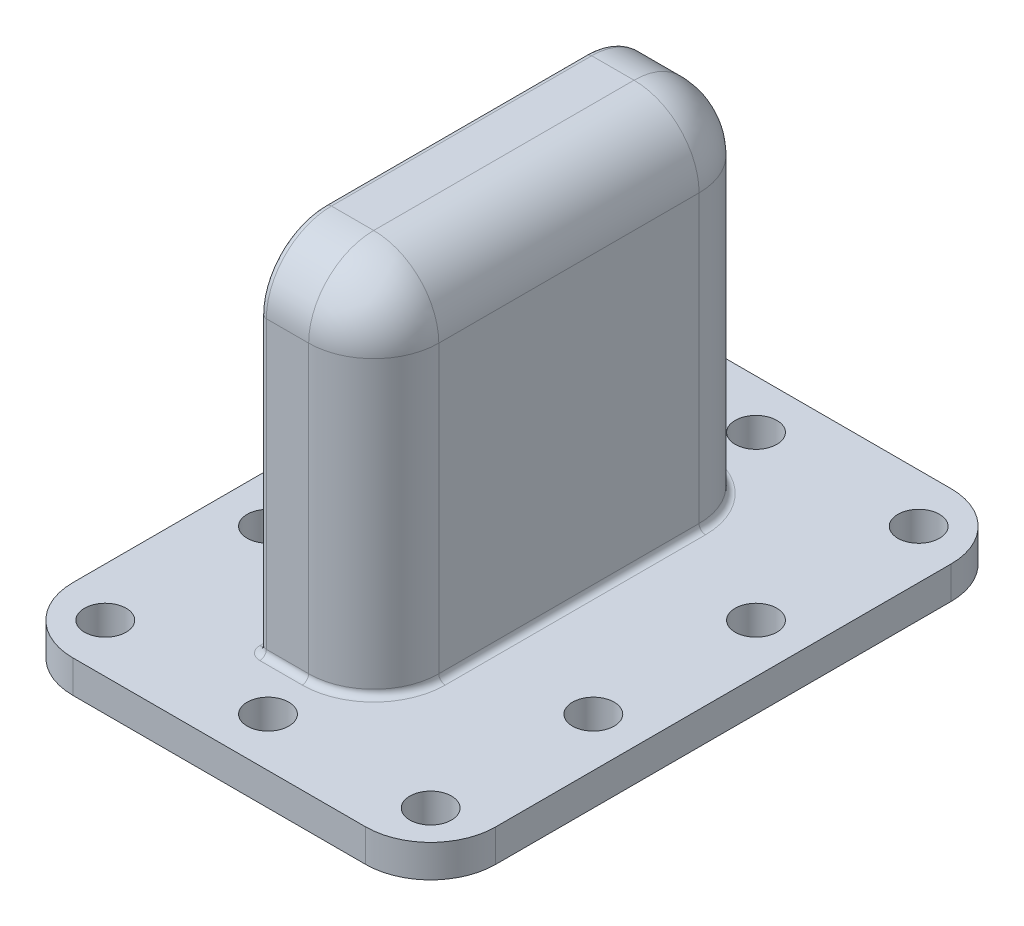
from build123d import *

# Parameters (mm, degrees)
SKETCH_1_W      = 65
SKETCH_1_H      = 90
SKETCH_1_R      = 3.2
EXTRUDE_1_DEPTH = 5
FILLET_1_R      = 10
SKETCH_2_W      = 17.5
SKETCH_2_H      = 60
EXTRUDE_2_DEPTH = 55
FILLET_2_R      = 10
FILLET_3_R      = 1


with BuildPart() as part:
    # 스케치1 → 보스-돌출1 (new body)
    with BuildSketch(Plane(origin=(0, 0, 0), x_dir=(1, 0, 0), z_dir=(0, 1, 0))):
        with Locations((0, -12.5)):
            Rectangle(SKETCH_1_W, SKETCH_1_H)
        with Locations((-25, 25)):
            Circle(SKETCH_1_R, mode=Mode.SUBTRACT)
        with Locations((25, 25)):
            Circle(SKETCH_1_R, mode=Mode.SUBTRACT)
        with Locations((25, 0)):
            Circle(SKETCH_1_R, mode=Mode.SUBTRACT)
        with Locations((-25, 0)):
            Circle(SKETCH_1_R, mode=Mode.SUBTRACT)
        with Locations((25, -50)):
            Circle(SKETCH_1_R, mode=Mode.SUBTRACT)
        with Locations((-25, -50)):
            Circle(SKETCH_1_R, mode=Mode.SUBTRACT)
        with Locations((0, 25)):
            Circle(SKETCH_1_R, mode=Mode.SUBTRACT)
        with Locations((0, -50)):
            Circle(SKETCH_1_R, mode=Mode.SUBTRACT)
        with Locations((25, -25)):
            Circle(SKETCH_1_R, mode=Mode.SUBTRACT)
        with Locations((-25, -25)):
            Circle(SKETCH_1_R, mode=Mode.SUBTRACT)
    extrude(amount=EXTRUDE_1_DEPTH)

    # 필렛1
    fillet_1_edges = [part.edges().sort_by_distance(p)[0] for p in [
        (-32.5, 2.5, -32.5),
        (32.5, 2.5, -32.5),
        (32.5, 2.5, 57.5),
        (-32.5, 2.5, 57.5),
    ]]
    fillet(fillet_1_edges, radius=FILLET_1_R)

    # 스케치2 → 보스-돌출2 (add)
    with BuildSketch(Plane(origin=(0, 5, 0), x_dir=(1, 0, 0), z_dir=(0, 1, 0))):
        with Locations((0, -12.5)):
            Rectangle(SKETCH_2_W, SKETCH_2_H)
    extrude(amount=EXTRUDE_2_DEPTH)

    # 필렛2
    fillet_2_edges = [part.edges().sort_by_distance(p)[0] for p in [
        (8.75, 32.5, 42.5),
        (8.75, 32.5, -17.5),
        (0, 60, -17.5),
        (0, 60, 42.5),
        (8.75, 60, 12.5),
    ]]
    fillet(fillet_2_edges, radius=FILLET_2_R)

    # 필렛3
    fillet_3_edges = [part.edges().sort_by_distance(p)[0] for p in [
        (-8.75, 57.071067812, -14.571067812),
        (5.821067812, 5, -14.571067812),
        (5.821067812, 5, 39.571067812),
        (-8.75, 5, 12.5),
        (-5, 5, 42.5),
        (-8.75, 60, 12.5),
        (8.75, 5, 12.5),
        (-5, 5, -17.5),
        (-8.75, 27.5, -17.5),
        (-8.75, 27.5, 42.5),
        (-8.75, 57.071067812, 39.571067812),
    ]]
    fillet(fillet_3_edges, radius=FILLET_3_R)


solid = part.part
